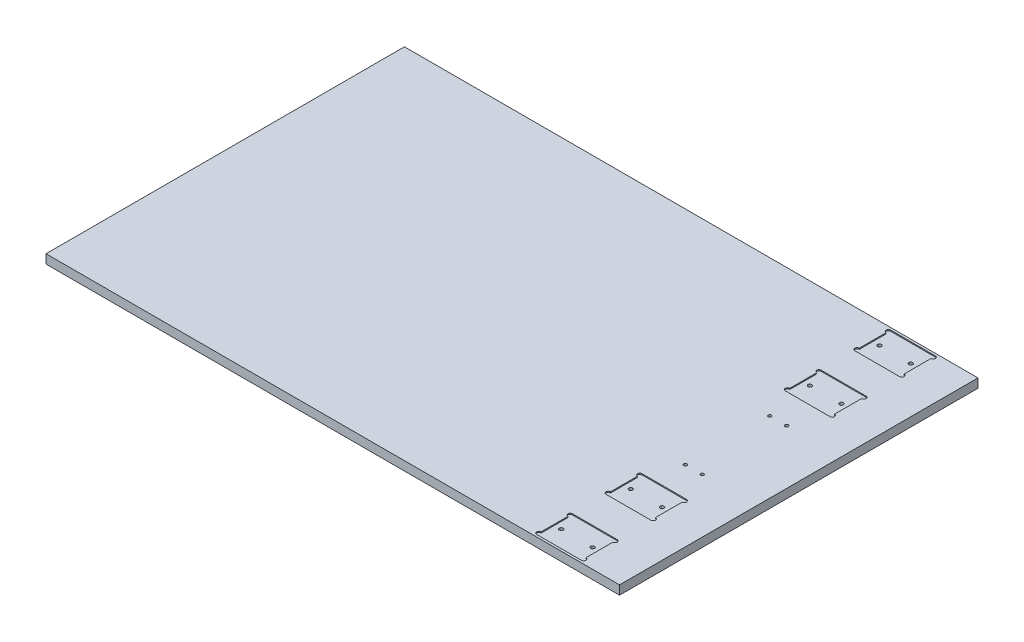
from build123d import *

# Parameters (mm, degrees)
SKETCH2_W           = 406.4
SKETCH2_H           = 6.35
BOSS_EXTRUDE1_DEPTH = 254
SKETCH3_R           = 1.3462
SKETCH3_R_2         = 1.1303
CUT_EXTRUDE1_DEPTH  = 7.35
CUT_EXTRUDE3_DEPTH  = 0.762


with BuildPart() as part:
    # Sketch2 → Boss-Extrude1 (new body)
    with BuildSketch(Plane.XY):
        with Locations((203.2, 3.175)):
            Rectangle(SKETCH2_W, SKETCH2_H)
    extrude(amount=-BOSS_EXTRUDE1_DEPTH)

    # Sketch3 → Cut-Extrude1 (cut, through all)
    with BuildSketch(Plane(origin=(0, 6.35, 0), x_dir=(1, 0, 0), z_dir=(0, 1, 0))):
        with Locations((350.8248, 239.7252)):
            Circle(SKETCH3_R)
        with Locations((373.0752, 239.7252)):
            Circle(SKETCH3_R)
        with Locations((373.0752, 190.5)):
            Circle(SKETCH3_R)
        with Locations((350.8248, 190.5)):
            Circle(SKETCH3_R)
        with Locations((355.9556, 156.9212)):
            Circle(SKETCH3_R_2)
        with Locations((367.9444, 156.9212)):
            Circle(SKETCH3_R_2)
        with Locations((367.9444, 97.0788)):
            Circle(SKETCH3_R_2)
        with Locations((355.9556, 97.0788)):
            Circle(SKETCH3_R_2)
        with Locations((373.0752, 63.5)):
            Circle(SKETCH3_R)
        with Locations((350.8248, 63.5)):
            Circle(SKETCH3_R)
        with Locations((350.8248, 14.2748)):
            Circle(SKETCH3_R)
        with Locations((373.0752, 14.2748)):
            Circle(SKETCH3_R)
    extrude(amount=-CUT_EXTRUDE1_DEPTH, mode=Mode.SUBTRACT)

    # Sketch4 → Cut-Extrude3 (cut)
    with BuildSketch(Plane(origin=(0, 6.35, 0), x_dir=(1, 0, 0), z_dir=(0, 1, 0))):
        with BuildLine():
            Line((346.075, 252.4252), (377.825, 252.4252))
            ThreePointArc((377.825, 252.4252), (379.4125, 250.8377), (377.825, 249.2502))
            Line((377.825, 249.2502), (377.825, 230.2002))
            ThreePointArc((377.825, 230.2002), (379.4125, 228.6127), (377.825, 227.0252))
            Line((377.825, 227.0252), (346.075, 227.0252))
            ThreePointArc((346.075, 227.0252), (344.4875, 228.6127), (346.075, 230.2002))
            Line((346.075, 230.2002), (346.075, 249.2502))
            ThreePointArc((346.075, 249.2502), (344.4875, 250.8377), (346.075, 252.4252))
        make_face()
        with BuildLine():
            Line((346.075, 203.2), (377.825, 203.2))
            ThreePointArc((377.825, 203.2), (379.4125, 201.6125), (377.825, 200.025))
            Line((377.825, 200.025), (377.825, 180.975))
            ThreePointArc((377.825, 180.975), (379.4125, 179.3875), (377.825, 177.8))
            Line((377.825, 177.8), (346.075, 177.8))
            ThreePointArc((346.075, 177.8), (344.4875, 179.3875), (346.075, 180.975))
            Line((346.075, 180.975), (346.075, 200.025))
            ThreePointArc((346.075, 200.025), (344.4875, 201.6125), (346.075, 203.2))
        make_face()
        with BuildLine():
            Line((346.075, 4.7498), (346.075, 23.7998))
            ThreePointArc((346.075, 23.7998), (344.4875, 25.3873), (346.075, 26.9748))
            Line((346.075, 26.9748), (377.825, 26.9748))
            ThreePointArc((377.825, 26.9748), (379.4125, 25.3873), (377.825, 23.7998))
            Line((377.825, 23.7998), (377.825, 4.7498))
            ThreePointArc((377.825, 4.7498), (379.4125, 3.1623), (377.825, 1.5748))
            Line((377.825, 1.5748), (346.075, 1.5748))
            ThreePointArc((346.075, 1.5748), (344.4875, 3.1623), (346.075, 4.7498))
        make_face()
        with BuildLine():
            Line((346.075, 53.975), (346.075, 73.025))
            ThreePointArc((346.075, 73.025), (344.4875, 74.6125), (346.075, 76.2))
            Line((346.075, 76.2), (377.825, 76.2))
            ThreePointArc((377.825, 76.2), (379.4125, 74.6125), (377.825, 73.025))
            Line((377.825, 73.025), (377.825, 53.975))
            ThreePointArc((377.825, 53.975), (379.4125, 52.3875), (377.825, 50.8))
            Line((377.825, 50.8), (346.075, 50.8))
            ThreePointArc((346.075, 50.8), (344.4875, 52.3875), (346.075, 53.975))
        make_face()
    extrude(amount=-CUT_EXTRUDE3_DEPTH, mode=Mode.SUBTRACT)


solid = part.part
